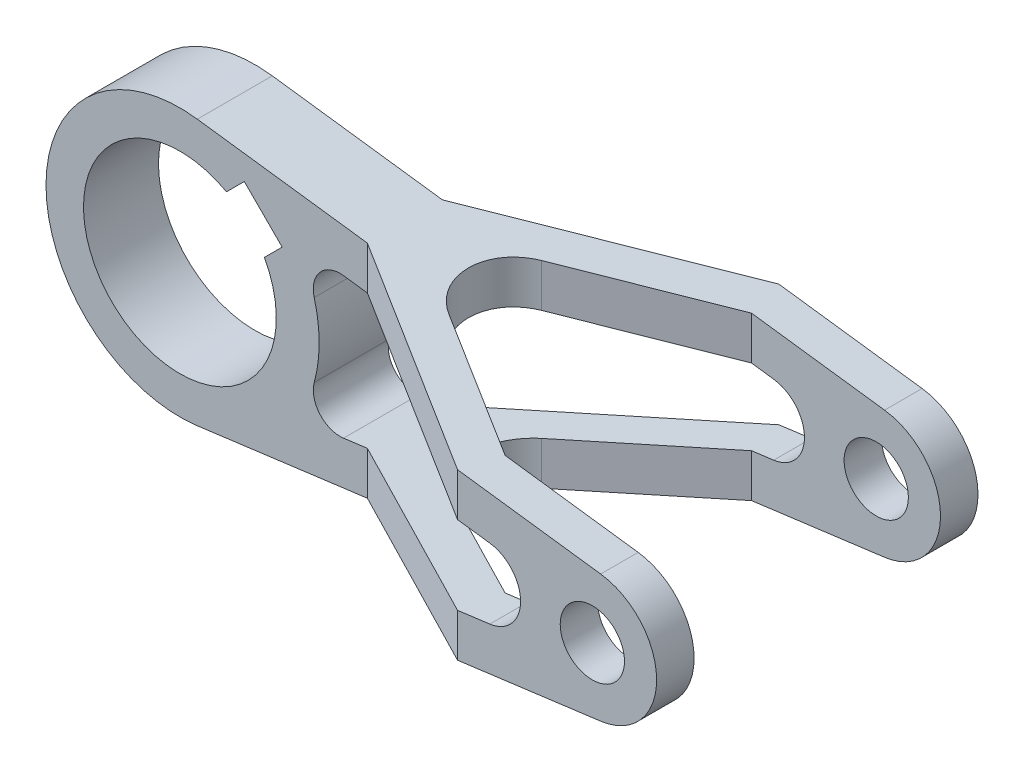
from build123d import *

# Parameters (mm, degrees)
SKETCH1_R               = 6
BOSS_EXTRUDE1_DEPTH     = 30
CUT_EXTRUDE1_DEPTH      = 61
SKETCH3_OUTSIDE_W       = 170.54
SKETCH3_OUTSIDE_H       = 93.54
CUT_EXTRUDE2_DEPTH      = 26
CUT_EXTRUDE2_DEPTH_BACK = 26
FILLET1_R               = 10


with BuildPart() as part:
    # Sketch1 → Boss-Extrude1 (new body, symmetric)
    with BuildSketch(Plane.XY):
        with BuildLine():
            Line((3.25, 24.787849846), (101.56, 11.898167926))
            ThreePointArc((101.56, 11.898167926), (112, 0), (101.56, -11.898167926))
            Line((101.56, -11.898167926), (3.25, -24.787849846))
            ThreePointArc((3.25, -24.787849846), (-25, 0), (3.25, 24.787849846))
        make_face()
        with Locations((100, 0)):
            Circle(SKETCH1_R, mode=Mode.SUBTRACT)
        with BuildLine():
            Line((8.691485355, 15.762553167), (12.02081528, 19.091883092))
            Line((12.02081528, 19.091883092), (19.091883092, 12.02081528))
            Line((19.091883092, 12.02081528), (15.762553167, 8.691485355))
            ThreePointArc((15.762553167, 8.691485355), (-12.727922061, -12.727922061), (8.691485355, 15.762553167))
        make_face(mode=Mode.SUBTRACT)
    extrude(amount=BOSS_EXTRUDE1_DEPTH, both=True)

    # Sketch2 → Cut-Extrude1 (cut, through all)
    with BuildSketch(Plane.XY.offset(30)):
        with BuildLine():
            Line((80.858, 6.543992359), (30.550654544, 13.139920354))
            ThreePointArc((30.550654544, 13.139920354), (26.131839925, 11.468082627), (25.077968327, 6.862616452))
            ThreePointArc((25.077968327, 6.862616452), (26, 0), (25.077968327, -6.862616452))
            ThreePointArc((25.077968327, -6.862616452), (26.131839925, -11.468082627), (30.550654544, -13.139920354))
            Line((30.550654544, -13.139920354), (80.858, -6.543992359))
            ThreePointArc((80.858, -6.543992359), (86.6, 0), (80.858, 6.543992359))
        make_face()
    extrude(amount=-CUT_EXTRUDE1_DEPTH, mode=Mode.SUBTRACT)

    # Sketch3 outside → Cut-Extrude2 (cut, two sides)
    with BuildSketch(Plane(origin=(0, 0, 0), x_dir=(1, 0, 0), z_dir=(0, 1, 0))) as cut_extrude2_sk:
        with Locations((43.5, 0)):
            Rectangle(SKETCH3_OUTSIDE_W, SKETCH3_OUTSIDE_H)
        Polygon((-25, 7), (35, 7), (74.837168574, 30), (112, 30), (112, 23), (76.712812921, 23), (36.875644347, 0), (76.712812921, -23), (112, -23), (112, -30), (74.837168574, -30), (35, -7), (-25, -7), align=None, mode=Mode.SUBTRACT)
    extrude(amount=CUT_EXTRUDE2_DEPTH, mode=Mode.SUBTRACT)
    extrude(cut_extrude2_sk.sketch, amount=-CUT_EXTRUDE2_DEPTH_BACK, mode=Mode.SUBTRACT)

    # Fillet1
    fillet1_edges = [part.edges().sort_by_distance(p)[0] for p in [
        (36.875644347, -16.344868893, 0),
        (36.875644347, 16.344868893, 0),
    ]]
    fillet(fillet1_edges, radius=FILLET1_R)


solid = part.part
